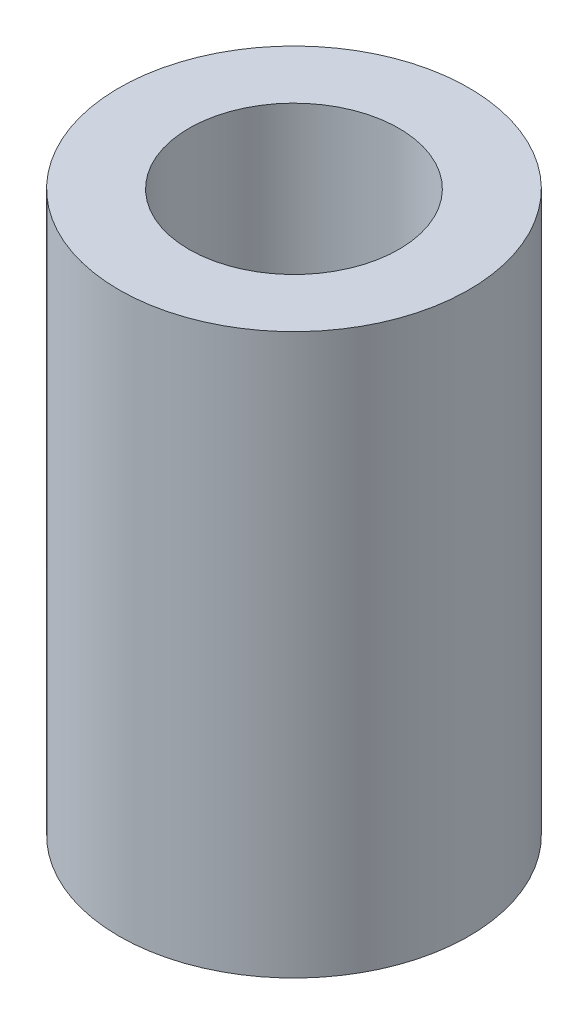
from build123d import *

# Parameters (mm, degrees)
ESQUISSE1_R      = 1.25
ESQUISSE1_R_2    = 0.75
EXTRUSION1_DEPTH = 4


with BuildPart() as part:
    # Esquisse1 → Extrusion1 (new body)
    with BuildSketch(Plane(origin=(0, 0, 0), x_dir=(1, 0, 0), z_dir=(0, 1, 0))):
        with Locations(Location((0, 0, 0), (0, 0, 270))):  # turned: the seam where the file's is
            Circle(ESQUISSE1_R)
        with Locations(Location((0, 0, 0), (0, 0, 270))):  # turned: the seam where the file's is
            Circle(ESQUISSE1_R_2, mode=Mode.SUBTRACT)
    extrude(amount=EXTRUSION1_DEPTH)


solid = part.part
